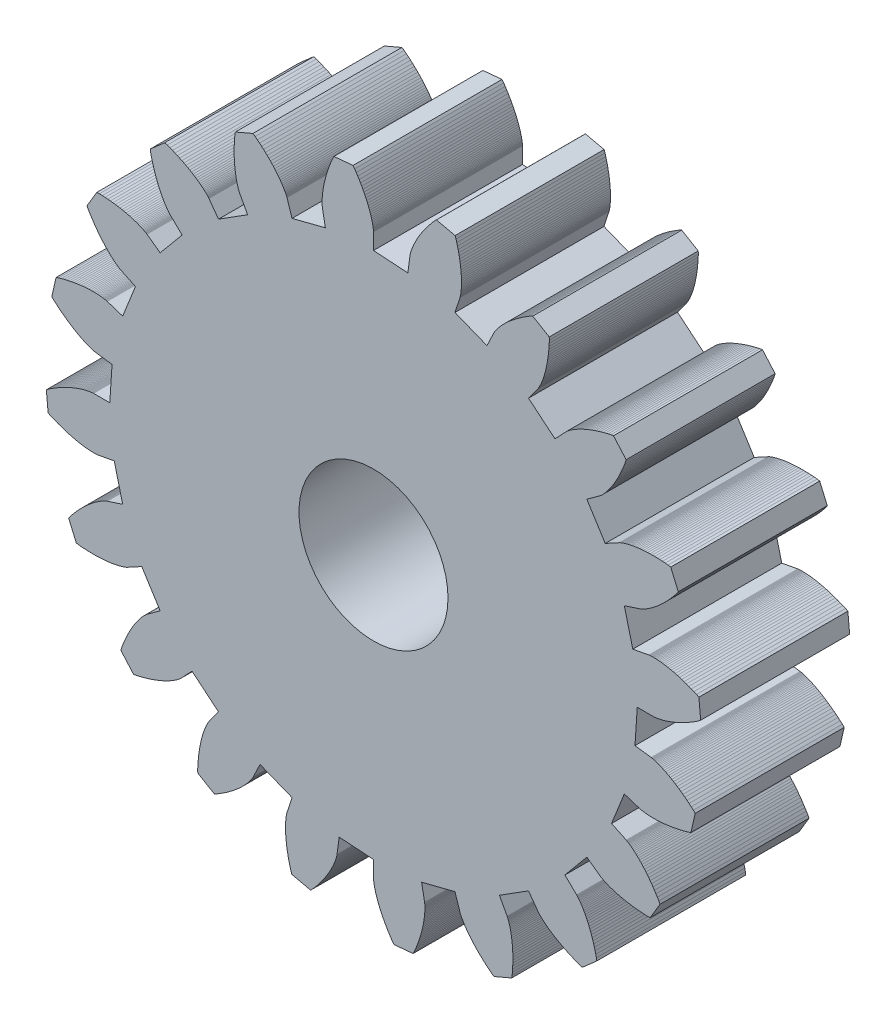
from build123d import *

# Parameters (mm, degrees)
MODEL_R         = 2.5
EXTRUDE_1_DEPTH = 5


with BuildPart() as part:
    # Model → 填料-伸長1 (new body)
    with BuildSketch(Plane.XY):
        Polygon((8.85, 0), (9.3984, 0), (9.4026, 0.0001), (9.4098, 0.0004), (9.4198, 0.0011), (9.4326, 0.0021), (9.4483, 0.0036), (9.4668, 0.0057), (9.4881, 0.0085), (9.5121, 0.0121), (9.539, 0.0166), (9.5685, 0.0221), (9.6008, 0.0287), (9.6357, 0.0364), (9.6733, 0.0454), (9.7135, 0.0558), (9.7562, 0.0677), (9.8015, 0.0811), (9.8493, 0.0962), (9.8995, 0.113), (9.9521, 0.1316), (10.0071, 0.1522), (10.0643, 0.1747), (10.1238, 0.1994), (10.1855, 0.2262), (10.2493, 0.2553), (10.3152, 0.2867), (10.3831, 0.3206), (10.4529, 0.3569), (10.5246, 0.3958), (10.5981, 0.4374), (10.6733, 0.4817), (10.7502, 0.5289), (10.8286, 0.5788), (10.9086, 0.6318), (10.9785, 0.687), (10.9195, 1.3281), (10.8407, 1.3696), (10.7524, 1.4071), (10.6662, 1.4419), (10.582, 1.4742), (10.4999, 1.504), (10.4201, 1.5315), (10.3425, 1.5567), (10.2672, 1.5797), (10.1943, 1.6006), (10.1238, 1.6195), (10.0557, 1.6364), (9.9902, 1.6516), (9.9272, 1.6649), (9.8668, 1.6767), (9.809, 1.6868), (9.7539, 1.6956), (9.7014, 1.7029), (9.6517, 1.709), (9.6047, 1.7139), (9.5605, 1.7178), (9.5191, 1.7207), (9.4805, 1.7227), (9.4448, 1.724), (9.4119, 1.7245), (9.3818, 1.7245), (9.3546, 1.724), (9.3303, 1.7232), (9.3089, 1.7221), (9.2903, 1.7208), (9.2746, 1.7194), (9.2618, 1.718), (9.2519, 1.7168), (9.2448, 1.7158), (9.2405, 1.7152), (8.7014, 1.6151), (8.4169, 2.7348), (8.9384, 2.9043), (8.9424, 2.9057), (8.9491, 2.9082), (8.9584, 2.9119), (8.9703, 2.9168), (8.9848, 2.9231), (9.0017, 2.9308), (9.0211, 2.9401), (9.0428, 2.9509), (9.067, 2.9635), (9.0934, 2.9778), (9.122, 2.994), (9.1528, 3.0122), (9.1858, 3.0324), (9.2208, 3.0547), (9.2578, 3.0792), (9.2967, 3.106), (9.3375, 3.1351), (9.3801, 3.1666), (9.4243, 3.2005), (9.4703, 3.2371), (9.5177, 3.2762), (9.5667, 3.318), (9.6171, 3.3626), (9.6688, 3.41), (9.7217, 3.4603), (9.7758, 3.5134), (9.831, 3.5696), (9.8872, 3.6287), (9.9442, 3.691), (10.0021, 3.7564), (10.0606, 3.825), (10.1198, 3.8967), (10.1795, 3.9718), (10.2289, 4.0459), (9.9747, 4.6374), (9.8869, 4.6526), (9.7914, 4.6609), (9.6986, 4.6674), (9.6085, 4.6721), (9.5213, 4.6751), (9.4368, 4.6765), (9.3552, 4.6765), (9.2765, 4.6751), (9.2007, 4.6725), (9.1278, 4.6686), (9.0579, 4.6637), (8.9909, 4.6579), (8.9268, 4.6511), (8.8657, 4.6436), (8.8076, 4.6354), (8.7525, 4.6267), (8.7004, 4.6175), (8.6512, 4.6079), (8.605, 4.5981), (8.5618, 4.5881), (8.5215, 4.578), (8.4842, 4.568), (8.4498, 4.5582), (8.4183, 4.5485), (8.3897, 4.5392), (8.364, 4.5304), (8.3411, 4.5221), (8.3211, 4.5144), (8.3038, 4.5074), (8.2894, 4.5013), (8.2776, 4.496), (8.2685, 4.4918), (8.2621, 4.4886), (8.2582, 4.4867), (7.7764, 4.2249), (7.1598, 5.2019), (7.6034, 5.5242), (7.6068, 5.5268), (7.6124, 5.5313), (7.6202, 5.5377), (7.6299, 5.546), (7.6417, 5.5565), (7.6554, 5.5691), (7.671, 5.5838), (7.6884, 5.6009), (7.7074, 5.6203), (7.7281, 5.6421), (7.7503, 5.6664), (7.7741, 5.6932), (7.7991, 5.7226), (7.8255, 5.7546), (7.8532, 5.7893), (7.8819, 5.8268), (7.9117, 5.8671), (7.9424, 5.9102), (7.9741, 5.9562), (8.0064, 6.0051), (8.0395, 6.057), (8.0732, 6.1119), (8.1073, 6.1699), (8.1418, 6.2309), (8.1766, 6.2951), (8.2117, 6.3624), (8.2468, 6.4328), (8.2819, 6.5064), (8.3169, 6.5833), (8.3517, 6.6634), (8.3862, 6.7467), (8.4203, 6.8332), (8.4539, 6.923), (8.478, 7.0088), (8.0534, 7.4928), (7.9653, 7.4801), (7.8718, 7.4585), (7.7816, 7.4359), (7.6945, 7.4126), (7.6106, 7.3885), (7.5298, 7.3638), (7.4522, 7.3386), (7.3778, 7.3129), (7.3065, 7.287), (7.2384, 7.2608), (7.1734, 7.2345), (7.1115, 7.2082), (7.0526, 7.182), (6.9969, 7.156), (6.9441, 7.1303), (6.8944, 7.1049), (6.8477, 7.08), (6.8038, 7.0557), (6.7629, 7.0321), (6.7249, 7.0093), (6.6897, 6.9873), (6.6573, 6.9662), (6.6277, 6.9462), (6.6007, 6.9273), (6.5764, 6.9096), (6.5547, 6.8933), (6.5355, 6.8783), (6.5188, 6.8648), (6.5046, 6.8528), (6.4927, 6.8425), (6.4831, 6.8339), (6.4758, 6.827), (6.4706, 6.8221), (6.4676, 6.819), (6.0902, 6.4212), (5.2019, 7.1598), (5.5242, 7.6034), (5.5266, 7.607), (5.5306, 7.613), (5.536, 7.6214), (5.5427, 7.6324), (5.5507, 7.646), (5.5598, 7.6622), (5.5701, 7.681), (5.5813, 7.7026), (5.5934, 7.7269), (5.6064, 7.7541), (5.62, 7.784), (5.6343, 7.8168), (5.6491, 7.8525), (5.6643, 7.8912), (5.6798, 7.9327), (5.6956, 7.9772), (5.7115, 8.0247), (5.7274, 8.0753), (5.7432, 8.1288), (5.7589, 8.1853), (5.7743, 8.2449), (5.7893, 8.3075), (5.8039, 8.3732), (5.8179, 8.4419), (5.8312, 8.5137), (5.8437, 8.5885), (5.8553, 8.6664), (5.866, 8.7472), (5.8755, 8.8311), (5.8839, 8.918), (5.8909, 9.0079), (5.8966, 9.1008), (5.9008, 9.1966), (5.8972, 9.2856), (5.3439, 9.6147), (5.2639, 9.5754), (5.1818, 9.526), (5.1029, 9.4766), (5.0273, 9.4275), (4.9549, 9.3787), (4.8857, 9.3302), (4.8198, 9.2823), (4.7569, 9.2349), (4.6971, 9.1882), (4.6404, 9.1422), (4.5867, 9.0971), (4.536, 9.053), (4.4881, 9.0099), (4.4431, 8.9679), (4.4009, 8.9271), (4.3614, 8.8877), (4.3247, 8.8496), (4.2905, 8.8129), (4.2589, 8.7778), (4.2298, 8.7443), (4.2031, 8.7125), (4.1788, 8.6825), (4.1568, 8.6543), (4.137, 8.628), (4.1193, 8.6037), (4.1037, 8.5814), (4.0901, 8.5612), (4.0784, 8.5432), (4.0686, 8.5274), (4.0605, 8.514), (4.054, 8.5028), (4.0492, 8.494), (4.0458, 8.4877), (4.0438, 8.4839), (3.8079, 7.9889), (2.7348, 8.4169), (2.9042, 8.9384), (2.9055, 8.9425), (2.9074, 8.9494), (2.9099, 8.9591), (2.9129, 8.9716), (2.9163, 8.987), (2.92, 9.0052), (2.9239, 9.0263), (2.9279, 9.0503), (2.9319, 9.0772), (2.9358, 9.107), (2.9396, 9.1397), (2.943, 9.1753), (2.946, 9.2139), (2.9485, 9.2553), (2.9505, 9.2996), (2.9517, 9.3468), (2.9521, 9.3969), (2.9517, 9.4499), (2.9502, 9.5057), (2.9476, 9.5643), (2.9439, 9.6257), (2.9388, 9.6899), (2.9324, 9.7569), (2.9244, 9.8266), (2.9149, 9.8989), (2.9037, 9.974), (2.8907, 10.0516), (2.8758, 10.1318), (2.859, 10.2146), (2.8401, 10.2998), (2.819, 10.3875), (2.7957, 10.4775), (2.7701, 10.5699), (2.7392, 10.6535), (2.1112, 10.7955), (2.0474, 10.7334), (1.9845, 10.661), (1.9247, 10.5897), (1.868, 10.5196), (1.8142, 10.4508), (1.7634, 10.3834), (1.7155, 10.3173), (1.6703, 10.2529), (1.6279, 10.19), (1.5882, 10.1287), (1.5511, 10.0693), (1.5164, 10.0116), (1.4842, 9.9558), (1.4544, 9.902), (1.4269, 9.8502), (1.4015, 9.8004), (1.3783, 9.7528), (1.3572, 9.7074), (1.338, 9.6643), (1.3206, 9.6234), (1.3051, 9.5849), (1.2912, 9.5489), (1.279, 9.5152), (1.2683, 9.4841), (1.259, 9.4555), (1.2511, 9.4295), (1.2444, 9.4061), (1.2388, 9.3854), (1.2343, 9.3673), (1.2308, 9.352), (1.2281, 9.3394), (1.2262, 9.3296), (1.2249, 9.3225), (1.2243, 9.3183), (1.1528, 8.7746), (0, 8.85), (0, 9.3984), (-0.0001, 9.4026), (-0.0004, 9.4098), (-0.0011, 9.4198), (-0.0021, 9.4326), (-0.0036, 9.4483), (-0.0057, 9.4668), (-0.0085, 9.4881), (-0.0121, 9.5121), (-0.0166, 9.539), (-0.0221, 9.5685), (-0.0287, 9.6008), (-0.0364, 9.6357), (-0.0454, 9.6733), (-0.0558, 9.7135), (-0.0677, 9.7562), (-0.0811, 9.8015), (-0.0962, 9.8493), (-0.113, 9.8995), (-0.1316, 9.9521), (-0.1522, 10.0071), (-0.1747, 10.0643), (-0.1994, 10.1238), (-0.2262, 10.1855), (-0.2553, 10.2493), (-0.2867, 10.3152), (-0.3206, 10.3831), (-0.3569, 10.4529), (-0.3958, 10.5246), (-0.4374, 10.5981), (-0.4817, 10.6733), (-0.5289, 10.7502), (-0.5788, 10.8286), (-0.6318, 10.9086), (-0.687, 10.9785), (-1.3281, 10.9195), (-1.3696, 10.8407), (-1.4071, 10.7524), (-1.4419, 10.6662), (-1.4742, 10.582), (-1.504, 10.4999), (-1.5315, 10.4201), (-1.5567, 10.3425), (-1.5797, 10.2672), (-1.6006, 10.1943), (-1.6195, 10.1238), (-1.6364, 10.0557), (-1.6516, 9.9902), (-1.6649, 9.9272), (-1.6767, 9.8668), (-1.6868, 9.809), (-1.6956, 9.7539), (-1.7029, 9.7014), (-1.709, 9.6517), (-1.7139, 9.6047), (-1.7178, 9.5605), (-1.7207, 9.5191), (-1.7227, 9.4805), (-1.724, 9.4448), (-1.7245, 9.4119), (-1.7245, 9.3818), (-1.724, 9.3546), (-1.7232, 9.3303), (-1.7221, 9.3089), (-1.7208, 9.2903), (-1.7194, 9.2746), (-1.718, 9.2618), (-1.7168, 9.2519), (-1.7158, 9.2448), (-1.7152, 9.2405), (-1.6151, 8.7014), (-2.7348, 8.4169), (-2.9043, 8.9384), (-2.9057, 8.9424), (-2.9082, 8.9491), (-2.9119, 8.9584), (-2.9168, 8.9703), (-2.9231, 8.9848), (-2.9308, 9.0017), (-2.9401, 9.0211), (-2.9509, 9.0428), (-2.9635, 9.067), (-2.9778, 9.0934), (-2.994, 9.122), (-3.0122, 9.1528), (-3.0324, 9.1858), (-3.0547, 9.2208), (-3.0792, 9.2578), (-3.106, 9.2967), (-3.1351, 9.3375), (-3.1666, 9.3801), (-3.2005, 9.4243), (-3.2371, 9.4703), (-3.2762, 9.5177), (-3.318, 9.5667), (-3.3626, 9.6171), (-3.41, 9.6688), (-3.4603, 9.7217), (-3.5134, 9.7758), (-3.5696, 9.831), (-3.6287, 9.8872), (-3.691, 9.9442), (-3.7564, 10.0021), (-3.825, 10.0606), (-3.8967, 10.1198), (-3.9718, 10.1795), (-4.0459, 10.2289), (-4.6374, 9.9747), (-4.6526, 9.8869), (-4.6609, 9.7914), (-4.6674, 9.6986), (-4.6721, 9.6085), (-4.6751, 9.5213), (-4.6765, 9.4368), (-4.6765, 9.3552), (-4.6751, 9.2765), (-4.6725, 9.2007), (-4.6686, 9.1278), (-4.6637, 9.0579), (-4.6579, 8.9909), (-4.6511, 8.9268), (-4.6436, 8.8657), (-4.6354, 8.8076), (-4.6267, 8.7525), (-4.6175, 8.7004), (-4.6079, 8.6512), (-4.5981, 8.605), (-4.5881, 8.5618), (-4.578, 8.5215), (-4.568, 8.4842), (-4.5582, 8.4498), (-4.5485, 8.4183), (-4.5392, 8.3897), (-4.5304, 8.364), (-4.5221, 8.3411), (-4.5144, 8.3211), (-4.5074, 8.3038), (-4.5013, 8.2894), (-4.496, 8.2776), (-4.4918, 8.2685), (-4.4886, 8.2621), (-4.4867, 8.2582), (-4.2249, 7.7764), (-5.2019, 7.1598), (-5.5242, 7.6034), (-5.5268, 7.6068), (-5.5313, 7.6124), (-5.5377, 7.6202), (-5.546, 7.6299), (-5.5565, 7.6417), (-5.5691, 7.6554), (-5.5838, 7.671), (-5.6009, 7.6884), (-5.6203, 7.7074), (-5.6421, 7.7281), (-5.6664, 7.7503), (-5.6932, 7.7741), (-5.7226, 7.7991), (-5.7546, 7.8255), (-5.7893, 7.8532), (-5.8268, 7.8819), (-5.8671, 7.9117), (-5.9102, 7.9424), (-5.9562, 7.9741), (-6.0051, 8.0064), (-6.057, 8.0395), (-6.1119, 8.0732), (-6.1699, 8.1073), (-6.2309, 8.1418), (-6.2951, 8.1766), (-6.3624, 8.2117), (-6.4328, 8.2468), (-6.5064, 8.2819), (-6.5833, 8.3169), (-6.6634, 8.3517), (-6.7467, 8.3862), (-6.8332, 8.4203), (-6.923, 8.4539), (-7.0088, 8.478), (-7.4928, 8.0534), (-7.4801, 7.9653), (-7.4585, 7.8718), (-7.4359, 7.7816), (-7.4126, 7.6945), (-7.3885, 7.6106), (-7.3638, 7.5298), (-7.3386, 7.4522), (-7.3129, 7.3778), (-7.287, 7.3065), (-7.2608, 7.2384), (-7.2345, 7.1734), (-7.2082, 7.1115), (-7.182, 7.0526), (-7.156, 6.9969), (-7.1303, 6.9441), (-7.1049, 6.8944), (-7.08, 6.8477), (-7.0557, 6.8038), (-7.0321, 6.7629), (-7.0093, 6.7249), (-6.9873, 6.6897), (-6.9662, 6.6573), (-6.9462, 6.6277), (-6.9273, 6.6007), (-6.9096, 6.5764), (-6.8933, 6.5547), (-6.8783, 6.5355), (-6.8648, 6.5188), (-6.8528, 6.5046), (-6.8425, 6.4927), (-6.8339, 6.4831), (-6.827, 6.4758), (-6.8221, 6.4706), (-6.819, 6.4676), (-6.4212, 6.0902), (-7.1598, 5.2019), (-7.6034, 5.5242), (-7.607, 5.5266), (-7.613, 5.5306), (-7.6214, 5.536), (-7.6324, 5.5427), (-7.646, 5.5507), (-7.6622, 5.5598), (-7.681, 5.5701), (-7.7026, 5.5813), (-7.7269, 5.5934), (-7.7541, 5.6064), (-7.784, 5.62), (-7.8168, 5.6343), (-7.8525, 5.6491), (-7.8912, 5.6643), (-7.9327, 5.6798), (-7.9772, 5.6956), (-8.0247, 5.7115), (-8.0753, 5.7274), (-8.1288, 5.7432), (-8.1853, 5.7589), (-8.2449, 5.7743), (-8.3075, 5.7893), (-8.3732, 5.8039), (-8.4419, 5.8179), (-8.5137, 5.8312), (-8.5885, 5.8437), (-8.6664, 5.8553), (-8.7472, 5.866), (-8.8311, 5.8755), (-8.918, 5.8839), (-9.0079, 5.8909), (-9.1008, 5.8966), (-9.1966, 5.9008), (-9.2856, 5.8972), (-9.6147, 5.3439), (-9.5754, 5.2639), (-9.526, 5.1818), (-9.4766, 5.1029), (-9.4275, 5.0273), (-9.3787, 4.9549), (-9.3302, 4.8857), (-9.2823, 4.8198), (-9.2349, 4.7569), (-9.1882, 4.6971), (-9.1422, 4.6404), (-9.0971, 4.5867), (-9.053, 4.536), (-9.0099, 4.4881), (-8.9679, 4.4431), (-8.9271, 4.4009), (-8.8877, 4.3614), (-8.8496, 4.3247), (-8.8129, 4.2905), (-8.7778, 4.2589), (-8.7443, 4.2298), (-8.7125, 4.2031), (-8.6825, 4.1788), (-8.6543, 4.1568), (-8.628, 4.137), (-8.6037, 4.1193), (-8.5814, 4.1037), (-8.5612, 4.0901), (-8.5432, 4.0784), (-8.5274, 4.0686), (-8.514, 4.0605), (-8.5028, 4.054), (-8.494, 4.0492), (-8.4877, 4.0458), (-8.4839, 4.0438), (-7.9889, 3.8079), (-8.4169, 2.7348), (-8.9384, 2.9042), (-8.9425, 2.9055), (-8.9494, 2.9074), (-8.9591, 2.9099), (-8.9716, 2.9129), (-8.987, 2.9163), (-9.0052, 2.92), (-9.0263, 2.9239), (-9.0503, 2.9279), (-9.0772, 2.9319), (-9.107, 2.9358), (-9.1397, 2.9396), (-9.1753, 2.943), (-9.2139, 2.946), (-9.2553, 2.9485), (-9.2996, 2.9505), (-9.3468, 2.9517), (-9.3969, 2.9521), (-9.4499, 2.9517), (-9.5057, 2.9502), (-9.5643, 2.9476), (-9.6257, 2.9439), (-9.6899, 2.9388), (-9.7569, 2.9324), (-9.8266, 2.9244), (-9.8989, 2.9149), (-9.974, 2.9037), (-10.0516, 2.8907), (-10.1318, 2.8758), (-10.2146, 2.859), (-10.2998, 2.8401), (-10.3875, 2.819), (-10.4775, 2.7957), (-10.5699, 2.7701), (-10.6535, 2.7392), (-10.7955, 2.1112), (-10.7334, 2.0474), (-10.661, 1.9845), (-10.5897, 1.9247), (-10.5196, 1.868), (-10.4508, 1.8142), (-10.3834, 1.7634), (-10.3173, 1.7155), (-10.2529, 1.6703), (-10.19, 1.6279), (-10.1287, 1.5882), (-10.0693, 1.5511), (-10.0116, 1.5164), (-9.9558, 1.4842), (-9.902, 1.4544), (-9.8502, 1.4269), (-9.8004, 1.4015), (-9.7528, 1.3783), (-9.7074, 1.3572), (-9.6643, 1.338), (-9.6234, 1.3206), (-9.5849, 1.3051), (-9.5489, 1.2912), (-9.5152, 1.279), (-9.4841, 1.2683), (-9.4555, 1.259), (-9.4295, 1.2511), (-9.4061, 1.2444), (-9.3854, 1.2388), (-9.3673, 1.2343), (-9.352, 1.2308), (-9.3394, 1.2281), (-9.3296, 1.2262), (-9.3225, 1.2249), (-9.3183, 1.2243), (-8.7746, 1.1528), (-8.85, 0), (-9.3984, 0), (-9.4026, -0.0001), (-9.4098, -0.0004), (-9.4198, -0.0011), (-9.4326, -0.0021), (-9.4483, -0.0036), (-9.4668, -0.0057), (-9.4881, -0.0085), (-9.5121, -0.0121), (-9.539, -0.0166), (-9.5685, -0.0221), (-9.6008, -0.0287), (-9.6357, -0.0364), (-9.6733, -0.0454), (-9.7135, -0.0558), (-9.7562, -0.0677), (-9.8015, -0.0811), (-9.8493, -0.0962), (-9.8995, -0.113), (-9.9521, -0.1316), (-10.0071, -0.1522), (-10.0643, -0.1747), (-10.1238, -0.1994), (-10.1855, -0.2262), (-10.2493, -0.2553), (-10.3152, -0.2867), (-10.3831, -0.3206), (-10.4529, -0.3569), (-10.5246, -0.3958), (-10.5981, -0.4374), (-10.6733, -0.4817), (-10.7502, -0.5289), (-10.8286, -0.5788), (-10.9086, -0.6318), (-10.9785, -0.687), (-10.9195, -1.3281), (-10.8407, -1.3696), (-10.7524, -1.4071), (-10.6662, -1.4419), (-10.582, -1.4742), (-10.4999, -1.504), (-10.4201, -1.5315), (-10.3425, -1.5567), (-10.2672, -1.5797), (-10.1943, -1.6006), (-10.1238, -1.6195), (-10.0557, -1.6364), (-9.9902, -1.6516), (-9.9272, -1.6649), (-9.8668, -1.6767), (-9.809, -1.6868), (-9.7539, -1.6956), (-9.7014, -1.7029), (-9.6517, -1.709), (-9.6047, -1.7139), (-9.5605, -1.7178), (-9.5191, -1.7207), (-9.4805, -1.7227), (-9.4448, -1.724), (-9.4119, -1.7245), (-9.3818, -1.7245), (-9.3546, -1.724), (-9.3303, -1.7232), (-9.3089, -1.7221), (-9.2903, -1.7208), (-9.2746, -1.7194), (-9.2618, -1.718), (-9.2519, -1.7168), (-9.2448, -1.7158), (-9.2405, -1.7152), (-8.7014, -1.6151), (-8.4169, -2.7348), (-8.9384, -2.9043), (-8.9424, -2.9057), (-8.9491, -2.9082), (-8.9584, -2.9119), (-8.9703, -2.9168), (-8.9848, -2.9231), (-9.0017, -2.9308), (-9.0211, -2.9401), (-9.0428, -2.9509), (-9.067, -2.9635), (-9.0934, -2.9778), (-9.122, -2.994), (-9.1528, -3.0122), (-9.1858, -3.0324), (-9.2208, -3.0547), (-9.2578, -3.0792), (-9.2967, -3.106), (-9.3375, -3.1351), (-9.3801, -3.1666), (-9.4243, -3.2005), (-9.4703, -3.2371), (-9.5177, -3.2762), (-9.5667, -3.318), (-9.6171, -3.3626), (-9.6688, -3.41), (-9.7217, -3.4603), (-9.7758, -3.5134), (-9.831, -3.5696), (-9.8872, -3.6287), (-9.9442, -3.691), (-10.0021, -3.7564), (-10.0606, -3.825), (-10.1198, -3.8967), (-10.1795, -3.9718), (-10.2289, -4.0459), (-9.9747, -4.6374), (-9.8869, -4.6526), (-9.7914, -4.6609), (-9.6986, -4.6674), (-9.6085, -4.6721), (-9.5213, -4.6751), (-9.4368, -4.6765), (-9.3552, -4.6765), (-9.2765, -4.6751), (-9.2007, -4.6725), (-9.1278, -4.6686), (-9.0579, -4.6637), (-8.9909, -4.6579), (-8.9268, -4.6511), (-8.8657, -4.6436), (-8.8076, -4.6354), (-8.7525, -4.6267), (-8.7004, -4.6175), (-8.6512, -4.6079), (-8.605, -4.5981), (-8.5618, -4.5881), (-8.5215, -4.578), (-8.4842, -4.568), (-8.4498, -4.5582), (-8.4183, -4.5485), (-8.3897, -4.5392), (-8.364, -4.5304), (-8.3411, -4.5221), (-8.3211, -4.5144), (-8.3038, -4.5074), (-8.2894, -4.5013), (-8.2776, -4.496), (-8.2685, -4.4918), (-8.2621, -4.4886), (-8.2582, -4.4867), (-7.7764, -4.2249), (-7.1598, -5.2019), (-7.6034, -5.5242), (-7.6068, -5.5268), (-7.6124, -5.5313), (-7.6202, -5.5377), (-7.6299, -5.546), (-7.6417, -5.5565), (-7.6554, -5.5691), (-7.671, -5.5838), (-7.6884, -5.6009), (-7.7074, -5.6203), (-7.7281, -5.6421), (-7.7503, -5.6664), (-7.7741, -5.6932), (-7.7991, -5.7226), (-7.8255, -5.7546), (-7.8532, -5.7893), (-7.8819, -5.8268), (-7.9117, -5.8671), (-7.9424, -5.9102), (-7.9741, -5.9562), (-8.0064, -6.0051), (-8.0395, -6.057), (-8.0732, -6.1119), (-8.1073, -6.1699), (-8.1418, -6.2309), (-8.1766, -6.2951), (-8.2117, -6.3624), (-8.2468, -6.4328), (-8.2819, -6.5064), (-8.3169, -6.5833), (-8.3517, -6.6634), (-8.3862, -6.7467), (-8.4203, -6.8332), (-8.4539, -6.923), (-8.478, -7.0088), (-8.0534, -7.4928), (-7.9653, -7.4801), (-7.8718, -7.4585), (-7.7816, -7.4359), (-7.6945, -7.4126), (-7.6106, -7.3885), (-7.5298, -7.3638), (-7.4522, -7.3386), (-7.3778, -7.3129), (-7.3065, -7.287), (-7.2384, -7.2608), (-7.1734, -7.2345), (-7.1115, -7.2082), (-7.0526, -7.182), (-6.9969, -7.156), (-6.9441, -7.1303), (-6.8944, -7.1049), (-6.8477, -7.08), (-6.8038, -7.0557), (-6.7629, -7.0321), (-6.7249, -7.0093), (-6.6897, -6.9873), (-6.6573, -6.9662), (-6.6277, -6.9462), (-6.6007, -6.9273), (-6.5764, -6.9096), (-6.5547, -6.8933), (-6.5355, -6.8783), (-6.5188, -6.8648), (-6.5046, -6.8528), (-6.4927, -6.8425), (-6.4831, -6.8339), (-6.4758, -6.827), (-6.4706, -6.8221), (-6.4676, -6.819), (-6.0902, -6.4212), (-5.2019, -7.1598), (-5.5242, -7.6034), (-5.5266, -7.607), (-5.5306, -7.613), (-5.536, -7.6214), (-5.5427, -7.6324), (-5.5507, -7.646), (-5.5598, -7.6622), (-5.5701, -7.681), (-5.5813, -7.7026), (-5.5934, -7.7269), (-5.6064, -7.7541), (-5.62, -7.784), (-5.6343, -7.8168), (-5.6491, -7.8525), (-5.6643, -7.8912), (-5.6798, -7.9327), (-5.6956, -7.9772), (-5.7115, -8.0247), (-5.7274, -8.0753), (-5.7432, -8.1288), (-5.7589, -8.1853), (-5.7743, -8.2449), (-5.7893, -8.3075), (-5.8039, -8.3732), (-5.8179, -8.4419), (-5.8312, -8.5137), (-5.8437, -8.5885), (-5.8553, -8.6664), (-5.866, -8.7472), (-5.8755, -8.8311), (-5.8839, -8.918), (-5.8909, -9.0079), (-5.8966, -9.1008), (-5.9008, -9.1966), (-5.8972, -9.2856), (-5.3439, -9.6147), (-5.2639, -9.5754), (-5.1818, -9.526), (-5.1029, -9.4766), (-5.0273, -9.4275), (-4.9549, -9.3787), (-4.8857, -9.3302), (-4.8198, -9.2823), (-4.7569, -9.2349), (-4.6971, -9.1882), (-4.6404, -9.1422), (-4.5867, -9.0971), (-4.536, -9.053), (-4.4881, -9.0099), (-4.4431, -8.9679), (-4.4009, -8.9271), (-4.3614, -8.8877), (-4.3247, -8.8496), (-4.2905, -8.8129), (-4.2589, -8.7778), (-4.2298, -8.7443), (-4.2031, -8.7125), (-4.1788, -8.6825), (-4.1568, -8.6543), (-4.137, -8.628), (-4.1193, -8.6037), (-4.1037, -8.5814), (-4.0901, -8.5612), (-4.0784, -8.5432), (-4.0686, -8.5274), (-4.0605, -8.514), (-4.054, -8.5028), (-4.0492, -8.494), (-4.0458, -8.4877), (-4.0438, -8.4839), (-3.8079, -7.9889), (-2.7348, -8.4169), (-2.9042, -8.9384), (-2.9055, -8.9425), (-2.9074, -8.9494), (-2.9099, -8.9591), (-2.9129, -8.9716), (-2.9163, -8.987), (-2.92, -9.0052), (-2.9239, -9.0263), (-2.9279, -9.0503), (-2.9319, -9.0772), (-2.9358, -9.107), (-2.9396, -9.1397), (-2.943, -9.1753), (-2.946, -9.2139), (-2.9485, -9.2553), (-2.9505, -9.2996), (-2.9517, -9.3468), (-2.9521, -9.3969), (-2.9517, -9.4499), (-2.9502, -9.5057), (-2.9476, -9.5643), (-2.9439, -9.6257), (-2.9388, -9.6899), (-2.9324, -9.7569), (-2.9244, -9.8266), (-2.9149, -9.8989), (-2.9037, -9.974), (-2.8907, -10.0516), (-2.8758, -10.1318), (-2.859, -10.2146), (-2.8401, -10.2998), (-2.819, -10.3875), (-2.7957, -10.4775), (-2.7701, -10.5699), (-2.7392, -10.6535), (-2.1112, -10.7955), (-2.0474, -10.7334), (-1.9845, -10.661), (-1.9247, -10.5897), (-1.868, -10.5196), (-1.8142, -10.4508), (-1.7634, -10.3834), (-1.7155, -10.3173), (-1.6703, -10.2529), (-1.6279, -10.19), (-1.5882, -10.1287), (-1.5511, -10.0693), (-1.5164, -10.0116), (-1.4842, -9.9558), (-1.4544, -9.902), (-1.4269, -9.8502), (-1.4015, -9.8004), (-1.3783, -9.7528), (-1.3572, -9.7074), (-1.338, -9.6643), (-1.3206, -9.6234), (-1.3051, -9.5849), (-1.2912, -9.5489), (-1.279, -9.5152), (-1.2683, -9.4841), (-1.259, -9.4555), (-1.2511, -9.4295), (-1.2444, -9.4061), (-1.2388, -9.3854), (-1.2343, -9.3673), (-1.2308, -9.352), (-1.2281, -9.3394), (-1.2262, -9.3296), (-1.2249, -9.3225), (-1.2243, -9.3183), (-1.1528, -8.7746), (0, -8.85), (0, -9.3984), (0.0001, -9.4026), (0.0004, -9.4098), (0.0011, -9.4198), (0.0021, -9.4326), (0.0036, -9.4483), (0.0057, -9.4668), (0.0085, -9.4881), (0.0121, -9.5121), (0.0166, -9.539), (0.0221, -9.5685), (0.0287, -9.6008), (0.0364, -9.6357), (0.0454, -9.6733), (0.0558, -9.7135), (0.0677, -9.7562), (0.0811, -9.8015), (0.0962, -9.8493), (0.113, -9.8995), (0.1316, -9.9521), (0.1522, -10.0071), (0.1747, -10.0643), (0.1994, -10.1238), (0.2262, -10.1855), (0.2553, -10.2493), (0.2867, -10.3152), (0.3206, -10.3831), (0.3569, -10.4529), (0.3958, -10.5246), (0.4374, -10.5981), (0.4817, -10.6733), (0.5289, -10.7502), (0.5788, -10.8286), (0.6318, -10.9086), (0.687, -10.9785), (1.3281, -10.9195), (1.3696, -10.8407), (1.4071, -10.7524), (1.4419, -10.6662), (1.4742, -10.582), (1.504, -10.4999), (1.5315, -10.4201), (1.5567, -10.3425), (1.5797, -10.2672), (1.6006, -10.1943), (1.6195, -10.1238), (1.6364, -10.0557), (1.6516, -9.9902), (1.6649, -9.9272), (1.6767, -9.8668), (1.6868, -9.809), (1.6956, -9.7539), (1.7029, -9.7014), (1.709, -9.6517), (1.7139, -9.6047), (1.7178, -9.5605), (1.7207, -9.5191), (1.7227, -9.4805), (1.724, -9.4448), (1.7245, -9.4119), (1.7245, -9.3818), (1.724, -9.3546), (1.7232, -9.3303), (1.7221, -9.3089), (1.7208, -9.2903), (1.7194, -9.2746), (1.718, -9.2618), (1.7168, -9.2519), (1.7158, -9.2448), (1.7152, -9.2405), (1.6151, -8.7014), (2.7348, -8.4169), (2.9043, -8.9384), (2.9057, -8.9424), (2.9082, -8.9491), (2.9119, -8.9584), (2.9168, -8.9703), (2.9231, -8.9848), (2.9308, -9.0017), (2.9401, -9.0211), (2.9509, -9.0428), (2.9635, -9.067), (2.9778, -9.0934), (2.994, -9.122), (3.0122, -9.1528), (3.0324, -9.1858), (3.0547, -9.2208), (3.0792, -9.2578), (3.106, -9.2967), (3.1351, -9.3375), (3.1666, -9.3801), (3.2005, -9.4243), (3.2371, -9.4703), (3.2762, -9.5177), (3.318, -9.5667), (3.3626, -9.6171), (3.41, -9.6688), (3.4603, -9.7217), (3.5134, -9.7758), (3.5696, -9.831), (3.6287, -9.8872), (3.691, -9.9442), (3.7564, -10.0021), (3.825, -10.0606), (3.8967, -10.1198), (3.9718, -10.1795), (4.0459, -10.2289), (4.6374, -9.9747), (4.6526, -9.8869), (4.6609, -9.7914), (4.6674, -9.6986), (4.6721, -9.6085), (4.6751, -9.5213), (4.6765, -9.4368), (4.6765, -9.3552), (4.6751, -9.2765), (4.6725, -9.2007), (4.6686, -9.1278), (4.6637, -9.0579), (4.6579, -8.9909), (4.6511, -8.9268), (4.6436, -8.8657), (4.6354, -8.8076), (4.6267, -8.7525), (4.6175, -8.7004), (4.6079, -8.6512), (4.5981, -8.605), (4.5881, -8.5618), (4.578, -8.5215), (4.568, -8.4842), (4.5582, -8.4498), (4.5485, -8.4183), (4.5392, -8.3897), (4.5304, -8.364), (4.5221, -8.3411), (4.5144, -8.3211), (4.5074, -8.3038), (4.5013, -8.2894), (4.496, -8.2776), (4.4918, -8.2685), (4.4886, -8.2621), (4.4867, -8.2582), (4.2249, -7.7764), (5.2019, -7.1598), (5.5242, -7.6034), (5.5268, -7.6068), (5.5313, -7.6124), (5.5377, -7.6202), (5.546, -7.6299), (5.5565, -7.6417), (5.5691, -7.6554), (5.5838, -7.671), (5.6009, -7.6884), (5.6203, -7.7074), (5.6421, -7.7281), (5.6664, -7.7503), (5.6932, -7.7741), (5.7226, -7.7991), (5.7546, -7.8255), (5.7893, -7.8532), (5.8268, -7.8819), (5.8671, -7.9117), (5.9102, -7.9424), (5.9562, -7.9741), (6.0051, -8.0064), (6.057, -8.0395), (6.1119, -8.0732), (6.1699, -8.1073), (6.2309, -8.1418), (6.2951, -8.1766), (6.3624, -8.2117), (6.4328, -8.2468), (6.5064, -8.2819), (6.5833, -8.3169), (6.6634, -8.3517), (6.7467, -8.3862), (6.8332, -8.4203), (6.923, -8.4539), (7.0088, -8.478), (7.4928, -8.0534), (7.4801, -7.9653), (7.4585, -7.8718), (7.4359, -7.7816), (7.4126, -7.6945), (7.3885, -7.6106), (7.3638, -7.5298), (7.3386, -7.4522), (7.3129, -7.3778), (7.287, -7.3065), (7.2608, -7.2384), (7.2345, -7.1734), (7.2082, -7.1115), (7.182, -7.0526), (7.156, -6.9969), (7.1303, -6.9441), (7.1049, -6.8944), (7.08, -6.8477), (7.0557, -6.8038), (7.0321, -6.7629), (7.0093, -6.7249), (6.9873, -6.6897), (6.9662, -6.6573), (6.9462, -6.6277), (6.9273, -6.6007), (6.9096, -6.5764), (6.8933, -6.5547), (6.8783, -6.5355), (6.8648, -6.5188), (6.8528, -6.5046), (6.8425, -6.4927), (6.8339, -6.4831), (6.827, -6.4758), (6.8221, -6.4706), (6.819, -6.4676), (6.4212, -6.0902), (7.1598, -5.2019), (7.6034, -5.5242), (7.607, -5.5266), (7.613, -5.5306), (7.6214, -5.536), (7.6324, -5.5427), (7.646, -5.5507), (7.6622, -5.5598), (7.681, -5.5701), (7.7026, -5.5813), (7.7269, -5.5934), (7.7541, -5.6064), (7.784, -5.62), (7.8168, -5.6343), (7.8525, -5.6491), (7.8912, -5.6643), (7.9327, -5.6798), (7.9772, -5.6956), (8.0247, -5.7115), (8.0753, -5.7274), (8.1288, -5.7432), (8.1853, -5.7589), (8.2449, -5.7743), (8.3075, -5.7893), (8.3732, -5.8039), (8.4419, -5.8179), (8.5137, -5.8312), (8.5885, -5.8437), (8.6664, -5.8553), (8.7472, -5.866), (8.8311, -5.8755), (8.918, -5.8839), (9.0079, -5.8909), (9.1008, -5.8966), (9.1966, -5.9008), (9.2856, -5.8972), (9.6147, -5.3439), (9.5754, -5.2639), (9.526, -5.1818), (9.4766, -5.1029), (9.4275, -5.0273), (9.3787, -4.9549), (9.3302, -4.8857), (9.2823, -4.8198), (9.2349, -4.7569), (9.1882, -4.6971), (9.1422, -4.6404), (9.0971, -4.5867), (9.053, -4.536), (9.0099, -4.4881), (8.9679, -4.4431), (8.9271, -4.4009), (8.8877, -4.3614), (8.8496, -4.3247), (8.8129, -4.2905), (8.7778, -4.2589), (8.7443, -4.2298), (8.7125, -4.2031), (8.6825, -4.1788), (8.6543, -4.1568), (8.628, -4.137), (8.6037, -4.1193), (8.5814, -4.1037), (8.5612, -4.0901), (8.5432, -4.0784), (8.5274, -4.0686), (8.514, -4.0605), (8.5028, -4.054), (8.494, -4.0492), (8.4877, -4.0458), (8.4839, -4.0438), (7.9889, -3.8079), (8.4169, -2.7348), (8.9384, -2.9042), (8.9425, -2.9055), (8.9494, -2.9074), (8.9591, -2.9099), (8.9716, -2.9129), (8.987, -2.9163), (9.0052, -2.92), (9.0263, -2.9239), (9.0503, -2.9279), (9.0772, -2.9319), (9.107, -2.9358), (9.1397, -2.9396), (9.1753, -2.943), (9.2139, -2.946), (9.2553, -2.9485), (9.2996, -2.9505), (9.3468, -2.9517), (9.3969, -2.9521), (9.4499, -2.9517), (9.5057, -2.9502), (9.5643, -2.9476), (9.6257, -2.9439), (9.6899, -2.9388), (9.7569, -2.9324), (9.8266, -2.9244), (9.8989, -2.9149), (9.974, -2.9037), (10.0516, -2.8907), (10.1318, -2.8758), (10.2146, -2.859), (10.2998, -2.8401), (10.3875, -2.819), (10.4775, -2.7957), (10.5699, -2.7701), (10.6535, -2.7392), (10.7955, -2.1112), (10.7334, -2.0474), (10.661, -1.9845), (10.5897, -1.9247), (10.5196, -1.868), (10.4508, -1.8142), (10.3834, -1.7634), (10.3173, -1.7155), (10.2529, -1.6703), (10.19, -1.6279), (10.1287, -1.5882), (10.0693, -1.5511), (10.0116, -1.5164), (9.9558, -1.4842), (9.902, -1.4544), (9.8502, -1.4269), (9.8004, -1.4015), (9.7528, -1.3783), (9.7074, -1.3572), (9.6643, -1.338), (9.6234, -1.3206), (9.5849, -1.3051), (9.5489, -1.2912), (9.5152, -1.279), (9.4841, -1.2683), (9.4555, -1.259), (9.4295, -1.2511), (9.4061, -1.2444), (9.3854, -1.2388), (9.3673, -1.2343), (9.352, -1.2308), (9.3394, -1.2281), (9.3296, -1.2262), (9.3225, -1.2249), (9.3183, -1.2243), (8.7746, -1.1528), align=None)
        Circle(MODEL_R, mode=Mode.SUBTRACT)
    extrude(amount=EXTRUDE_1_DEPTH)


solid = part.part
